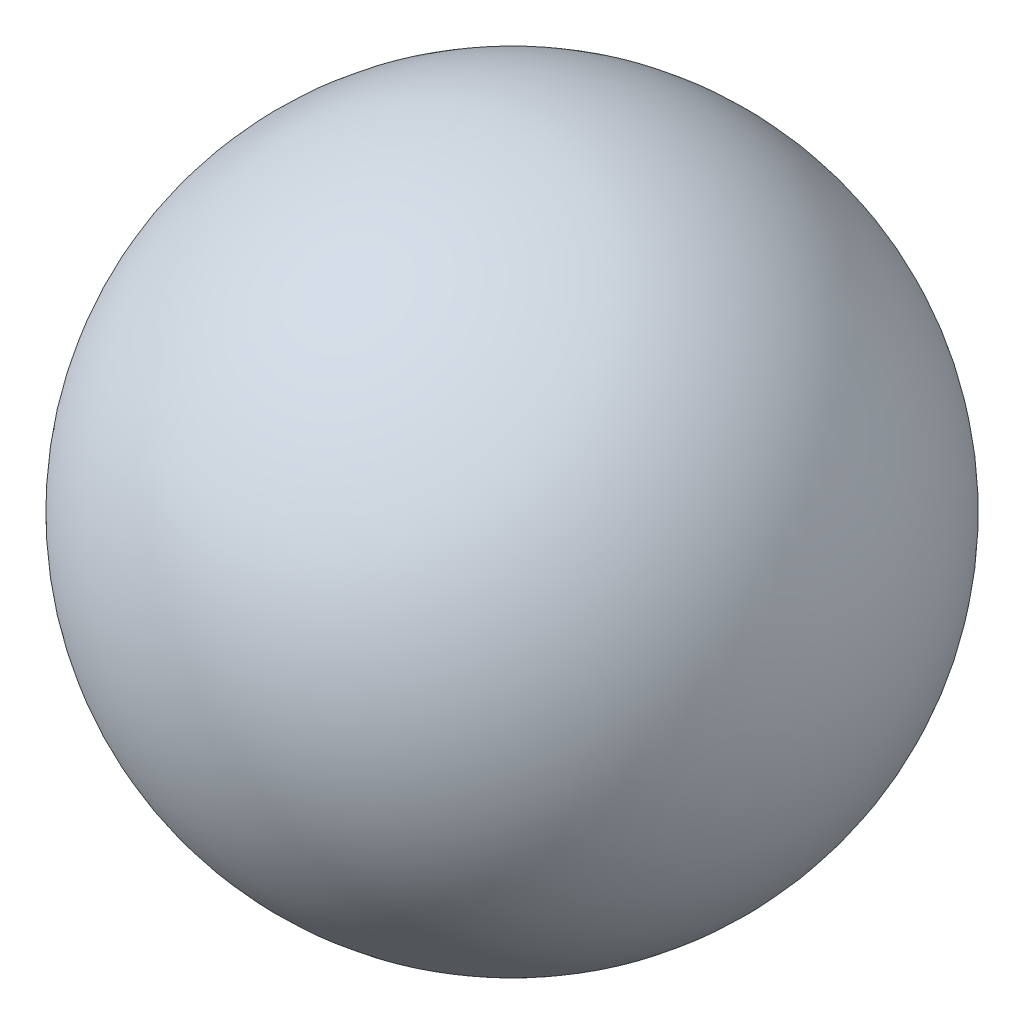
from build123d import *


with BuildPart() as part:
    # Sketch1 → Revolve2 (revolve)
    with BuildSketch(Plane.XY):
        with BuildLine():
            Line((0, 21.336), (0, -21.336))
            ThreePointArc((0, -21.336), (21.336, 0), (0, 21.336))
        make_face()
    revolve(axis=Axis((0, 23.4696, 0), (0, -1, 0)))


solid = part.part
